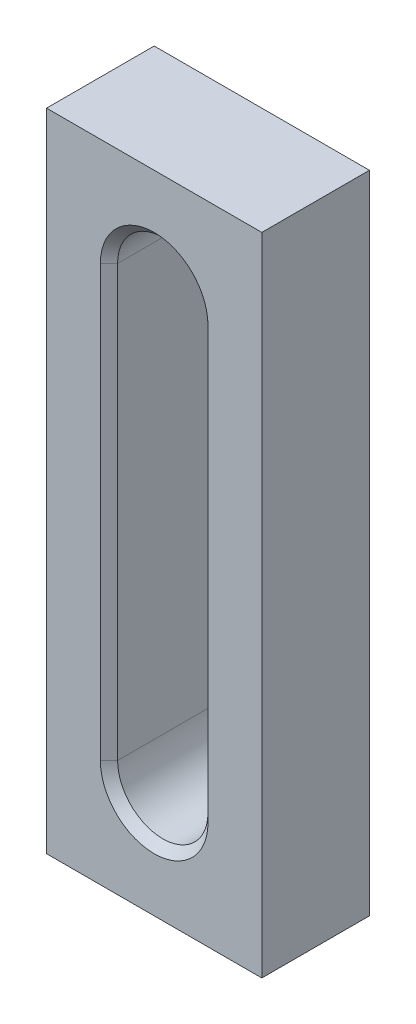
from build123d import *

# Parameters (mm, degrees)
SKETCH_1_W          = 50
SKETCH_1_H          = 150
EXTRUDE_1_DEPTH     = 25
CUT_EXTRUDE_1_DEPTH = 26
CHAMFER_1_SIZE      = 2


with BuildPart() as part:
    # Эскиз1 → Бобышка-Вытянуть1 (new body)
    with BuildSketch(Plane.XY):
        with Locations((25, 75)):
            Rectangle(SKETCH_1_W, SKETCH_1_H)
    extrude(amount=EXTRUDE_1_DEPTH)

    # Эскиз2 → Вырез-Вытянуть1 (cut, through all)
    with BuildSketch(Plane.XY.offset(25)):
        with BuildLine():
            Line((35.5, 125), (35.5, 25))
            ThreePointArc((35.5, 25), (25, 14.5), (14.5, 25))
            Line((14.5, 25), (14.5, 125))
            ThreePointArc((14.5, 125), (25, 135.5), (35.5, 125))
        make_face()
    extrude(amount=-CUT_EXTRUDE_1_DEPTH, mode=Mode.SUBTRACT)

    # Фаска1
    chamfer_1_edges = [part.edges().sort_by_distance(p)[0] for p in [
        (25, 14.5, 0),
        (14.5, 75, 0),
        (25, 135.5, 0),
        (35.5, 75, 0),
        (25, 14.5, 25),
        (35.5, 75, 25),
        (25, 135.5, 25),
        (14.5, 75, 25),
    ]]
    chamfer(chamfer_1_edges, length=CHAMFER_1_SIZE)


solid = part.part
